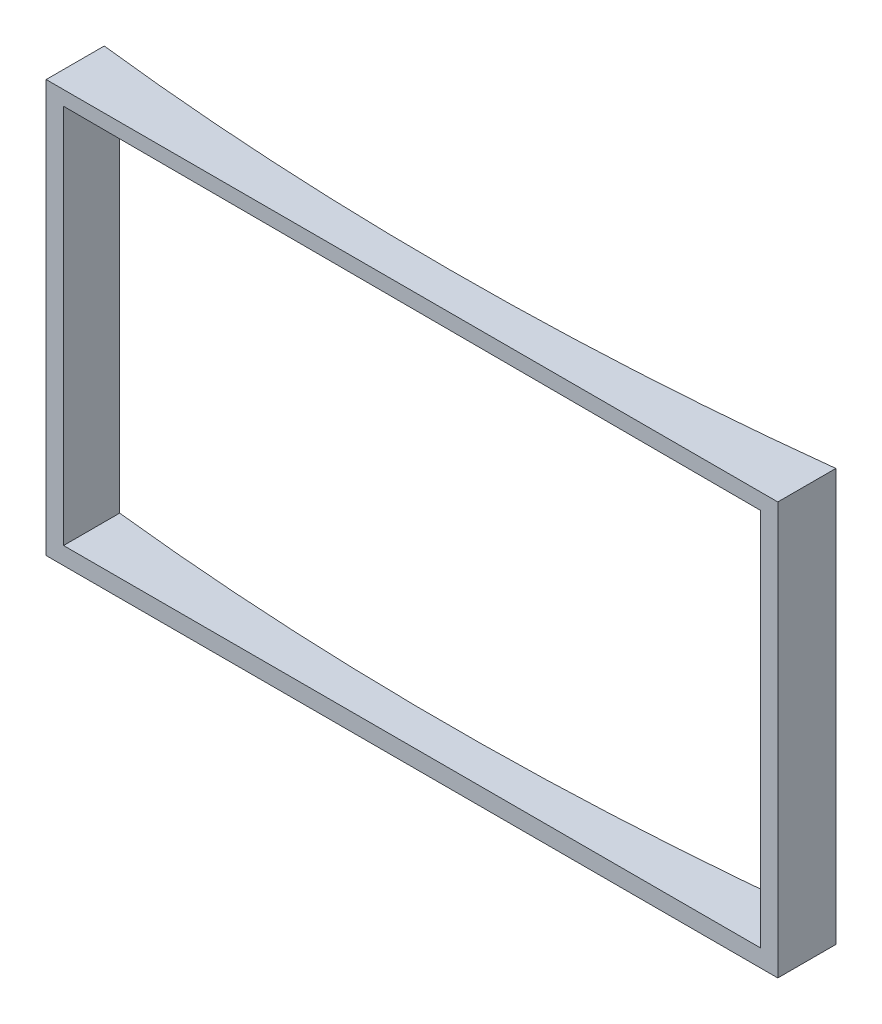
from build123d import *

# Parameters (mm, degrees)
BOSS_EXTRUDE1_DEPTH = 3550
CUT_EXTRUDE1_DEPTH  = 6000


with BuildPart() as part:
    # Sketch2 → Boss-Extrude1 (new body)
    with BuildSketch(Plane(origin=(0, 0, 0), x_dir=(1, 0, 0), z_dir=(0, 1, 0))):
        with BuildLine():
            Line((2590.546480495, -3013.609856922), (8890.546480495, -3013.609856922))
            Line((8890.546480495, -3013.609856922), (8890.546480495, -2513.609856922))
            ThreePointArc((8890.546480495, -2513.609856922), (5740.546480495, -2694.614633818), (2590.546480495, -2513.609856922))
            Line((2590.546480495, -2513.609856922), (2590.546480495, -3013.609856922))
        make_face()
    extrude(amount=BOSS_EXTRUDE1_DEPTH)

    # Sketch3 → Cut-Extrude1 (cut)
    with BuildSketch(Plane.XY.offset(3013.609856922)):
        Polygon((2740.546480495, 3425.61786483), (8740.546480495, 3412.63855525), (8740.546480495, 150), (2740.546480495, 150), align=None)
    extrude(amount=-CUT_EXTRUDE1_DEPTH, mode=Mode.SUBTRACT)


solid = part.part
